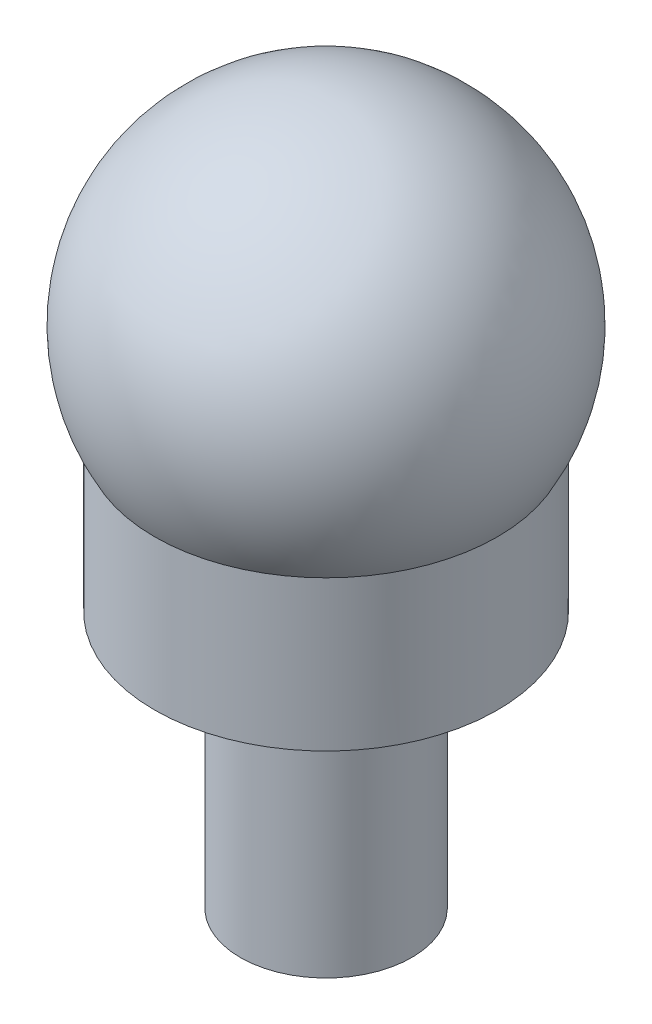
from build123d import *

# Parameters (mm, degrees)
SKETCH1_R           = 4
BOSS_EXTRUDE1_DEPTH = 12
SKETCH3_R           = 8
BOSS_EXTRUDE2_DEPTH = 7


with BuildPart() as part:
    # Sketch1 → Boss-Extrude1 (new body)
    with BuildSketch(Plane(origin=(0, 0, 0), x_dir=(1, 0, 0), z_dir=(0, 1, 0))):
        Circle(SKETCH1_R)
    extrude(amount=BOSS_EXTRUDE1_DEPTH)

    # Sketch3 → Boss-Extrude2 (add)
    with BuildSketch(Plane(origin=(0, 12, 0), x_dir=(1, 0, 0), z_dir=(0, 1, 0))):
        Circle(SKETCH3_R)
    extrude(amount=BOSS_EXTRUDE2_DEPTH)

    # Sketch4 → Revolve2 (revolve)
    with BuildSketch(Plane.XY):
        with BuildLine():
            Line((0, 28.11938617), (0, 19))
            Line((0, 19), (8, 19))
            ThreePointArc((8, 19), (7.961699903, 28.185937316), (0, 32.767885146))
            Line((0, 32.767885146), (0, 28.11938617))
        make_face()
    revolve(axis=Axis((0, 28.11938617, 0), (0, -1, 0)))


solid = part.part
